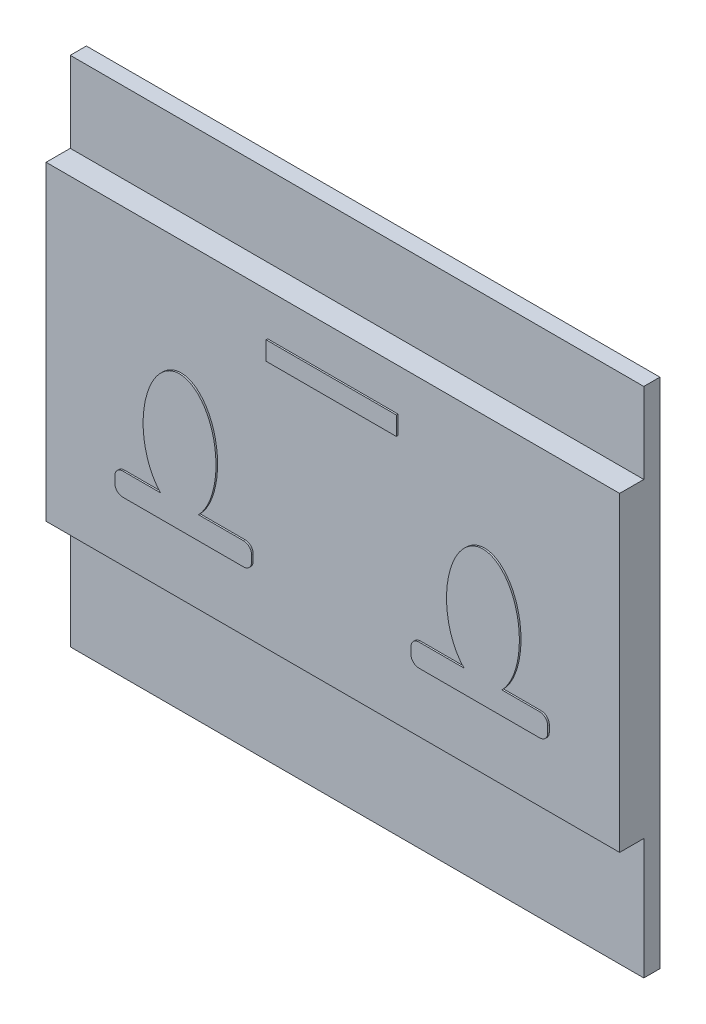
from build123d import *

# Parameters (mm, degrees)
SKETCH_1_W      = 35.6
SKETCH_1_H      = 31.8
EXTRUDE_1_DEPTH = 1
SKETCH_2_W      = 35.6
SKETCH_2_H      = 19.3
EXTRUDE_2_DEPTH = 1.5
SKETCH_3_W      = 8.082791172
SKETCH_3_H      = 1.155308412
EXTRUDE_3_DEPTH = 0.1


with BuildPart() as part:
    # 草图1 → 凸台-拉伸1 (new body)
    with BuildSketch(Plane.XY):
        Rectangle(SKETCH_1_W, SKETCH_1_H)
    extrude(amount=EXTRUDE_1_DEPTH)

    # 草图2 → 凸台-拉伸2 (add)
    with BuildSketch(Plane.XY.offset(1)):
        with Locations((0, 1.25)):
            Rectangle(SKETCH_2_W, SKETCH_2_H)
    extrude(amount=EXTRUDE_2_DEPTH)

    # 草图3 → 凸台-拉伸3 (add)
    with BuildSketch(Plane.XY.offset(2.5)):
        with BuildLine():
            Line((8.23788009, -3.216692679), (5.445549995, -3.216692679))
            ThreePointArc((5.445549995, -3.216692679), (5.091996605, -3.363139288), (4.945549995, -3.716692679))
            Line((4.945549995, -3.716692679), (4.945549995, -4.123155093))
            ThreePointArc((4.945549995, -4.123155093), (5.091996605, -4.476708484), (5.445549995, -4.623155093))
            Line((5.445549995, -4.623155093), (12.934555282, -4.623155093))
            ThreePointArc((12.934555282, -4.623155093), (13.288108672, -4.476708484), (13.434555282, -4.123155093))
            Line((13.434555282, -4.123155093), (13.434555282, -3.716692679))
            ThreePointArc((13.434555282, -3.716692679), (13.288108672, -3.363139288), (12.934555282, -3.216692679))
            Line((12.934555282, -3.216692679), (10.594302392, -3.216692679))
            add(Edge.make_bspline(
                [(10.594302392, -3.216692679), (17.453446302, 3.769231485), (9.416091241, 3.769231485), (1.37873618, 3.769231485), (8.23788009, -3.216692679)],
                knots=[0.54830721, 0.54830721, 0.54830721, 3.141592654, 3.141592654, 5.734878097, 5.734878097, 5.734878097], degree=2, weights=[1, 0.270732248, 1, 0.270732248, 1]))
        make_face()
        with Locations((0, 7.708506432)):
            Rectangle(SKETCH_3_W, SKETCH_3_H)
        with BuildLine():
            Line((-4.945549995, -4.123155093), (-4.945549995, -3.716692679))
            ThreePointArc((-4.945549995, -3.716692679), (-5.091996605, -3.363139288), (-5.445549995, -3.216692679))
            Line((-5.445549995, -3.216692679), (-8.23788009, -3.216692679))
            add(Edge.make_bspline(
                [(-8.23788009, -3.216692679), (-1.37873618, 3.769231485), (-9.416091241, 3.769231485), (-17.453446302, 3.769231485), (-10.594302392, -3.216692679)],
                knots=[0.54830721, 0.54830721, 0.54830721, 3.141592654, 3.141592654, 5.734878097, 5.734878097, 5.734878097], degree=2, weights=[1, 0.270732248, 1, 0.270732248, 1]))
            Line((-10.594302392, -3.216692679), (-12.934555282, -3.216692679))
            ThreePointArc((-12.934555282, -3.216692679), (-13.288108672, -3.363139288), (-13.434555282, -3.716692679))
            Line((-13.434555282, -3.716692679), (-13.434555282, -4.123155093))
            ThreePointArc((-13.434555282, -4.123155093), (-13.288108672, -4.476708484), (-12.934555282, -4.623155093))
            Line((-12.934555282, -4.623155093), (-5.445549995, -4.623155093))
            ThreePointArc((-5.445549995, -4.623155093), (-5.091996605, -4.476708484), (-4.945549995, -4.123155093))
        make_face()
    extrude(amount=EXTRUDE_3_DEPTH)


solid = part.part
